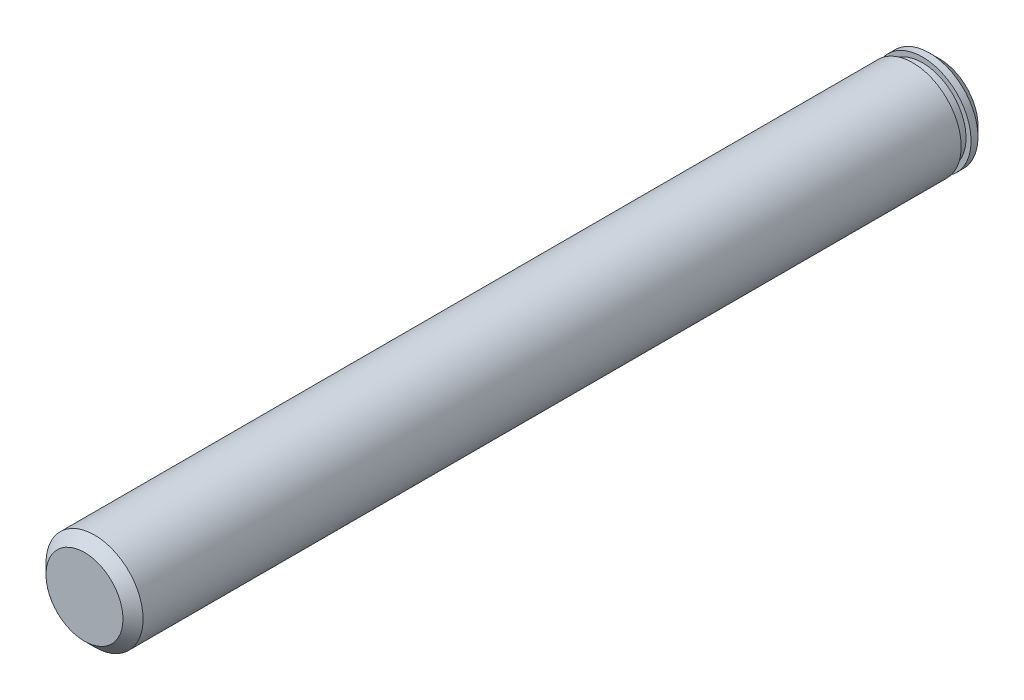
from build123d import *

# Parameters (mm, degrees)
SKETCH1_R           = 4.825
BOSS_EXTRUDE1_DEPTH = 85
CHAMFER2_SIZE       = 1
SKETCH3_W           = 0.5
SKETCH3_H           = 0.98


with BuildPart() as part:
    # Sketch1 → Boss-Extrude1 (new body)
    with BuildSketch(Plane.XY):
        Circle(SKETCH1_R)
    extrude(amount=BOSS_EXTRUDE1_DEPTH)

    # Chamfer2
    chamfer2_edges = [part.edges().sort_by_distance(p)[0] for p in [
        (-4.825, 0, 0),
        (-4.825, 0, 85),
    ]]
    chamfer(chamfer2_edges, length=CHAMFER2_SIZE)

    # Sketch3 → Cut-Revolve4 (revolve, cut)
    with BuildSketch(Plane(origin=(0, 0, 0), x_dir=(1, 0, 0), z_dir=(0, 1, 0))):
        with Locations((-4.575, -2.18)):
            Rectangle(SKETCH3_W, SKETCH3_H)
    revolve(axis=Axis((0, 0, 0), (0, 0, 1)), mode=Mode.SUBTRACT)


solid = part.part
